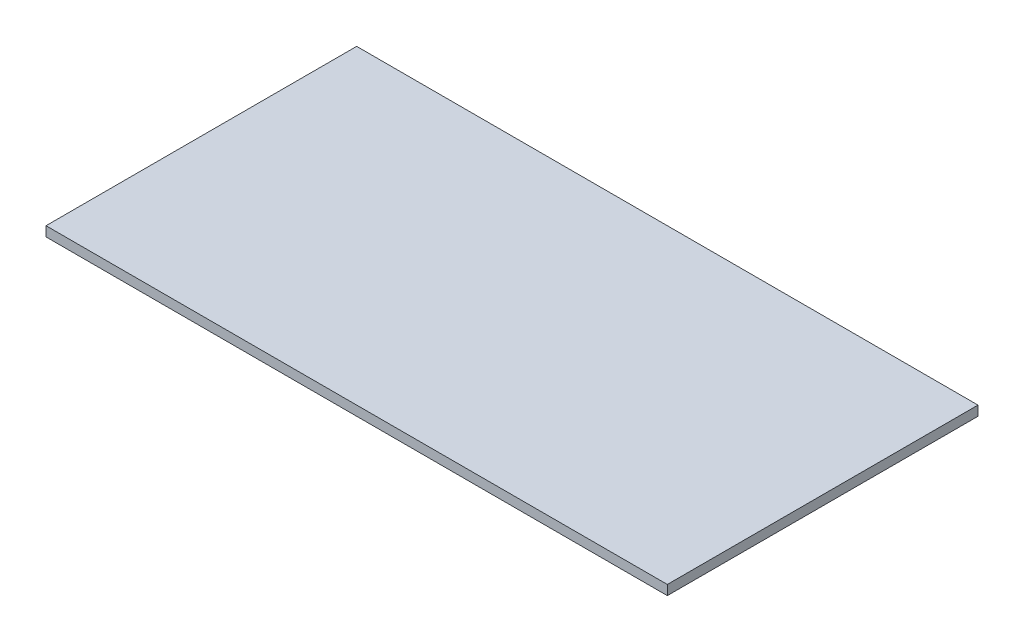
from build123d import *

# Parameters (mm, degrees)
SKETCH1_W           = 1219.2
SKETCH1_H           = 609.6
BOSS_EXTRUDE1_DEPTH = 19.05


with BuildPart() as part:
    # Sketch1 → Boss-Extrude1 (new body)
    with BuildSketch(Plane(origin=(0, 0, 0), x_dir=(1, 0, 0), z_dir=(0, 1, 0))):
        Rectangle(SKETCH1_W, SKETCH1_H)
    extrude(amount=BOSS_EXTRUDE1_DEPTH)


solid = part.part
